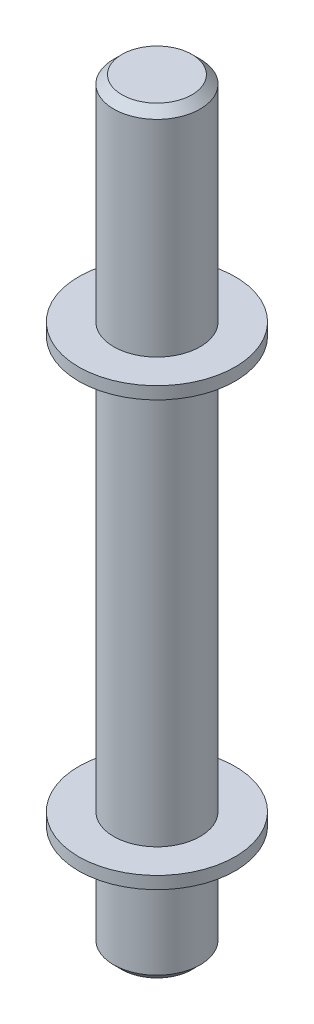
from build123d import *

# Parameters (mm, degrees)
SKETCH1_R           = 10.5
BOSS_EXTRUDE1_DEPTH = 26
BOSS_EXTRUDE2_START = 26
SKETCH1_3_R         = 19
BOSS_EXTRUDE2_DEPTH = 3
BOSS_EXTRUDE3_START = 29
SKETCH1_4_R         = 10.5
BOSS_EXTRUDE3_DEPTH = 100
BOSS_EXTRUDE4_START = 129
SKETCH1_5_R         = 19
BOSS_EXTRUDE4_DEPTH = 3
BOSS_EXTRUDE5_START = 132
SKETCH1_6_R         = 10.5
BOSS_EXTRUDE5_DEPTH = 52
CHAMFER1_SIZE       = 2


with BuildPart() as part:
    # Sketch1 → Boss-Extrude1 (new body)
    with BuildSketch(Plane(origin=(0, 0, 0), x_dir=(1, 0, 0), z_dir=(0, 1, 0))):
        Circle(SKETCH1_R)
    extrude(amount=BOSS_EXTRUDE1_DEPTH)

    # Sketch1_3 → Boss-Extrude2 (add)
    with BuildSketch(Plane(origin=(0, 0, 0), x_dir=(1, 0, 0), z_dir=(0, 1, 0)).offset(BOSS_EXTRUDE2_START)):
        Circle(SKETCH1_3_R)
    extrude(amount=BOSS_EXTRUDE2_DEPTH)

    # Sketch1_4 → Boss-Extrude3 (add)
    with BuildSketch(Plane(origin=(0, 0, 0), x_dir=(1, 0, 0), z_dir=(0, 1, 0)).offset(BOSS_EXTRUDE3_START)):
        Circle(SKETCH1_4_R)
    extrude(amount=BOSS_EXTRUDE3_DEPTH)

    # Sketch1_5 → Boss-Extrude4 (add)
    with BuildSketch(Plane(origin=(0, 0, 0), x_dir=(1, 0, 0), z_dir=(0, 1, 0)).offset(BOSS_EXTRUDE4_START)):
        Circle(SKETCH1_5_R)
    extrude(amount=BOSS_EXTRUDE4_DEPTH)

    # Sketch1_6 → Boss-Extrude5 (add)
    with BuildSketch(Plane(origin=(0, 0, 0), x_dir=(1, 0, 0), z_dir=(0, 1, 0)).offset(BOSS_EXTRUDE5_START)):
        Circle(SKETCH1_6_R)
    extrude(amount=BOSS_EXTRUDE5_DEPTH)

    # Chamfer1
    chamfer1_edges = [part.edges().sort_by_distance(p)[0] for p in [
        (-10.5, 184, 0),
        (-10.5, 0, 0),
    ]]
    chamfer(chamfer1_edges, length=CHAMFER1_SIZE)


solid = part.part
